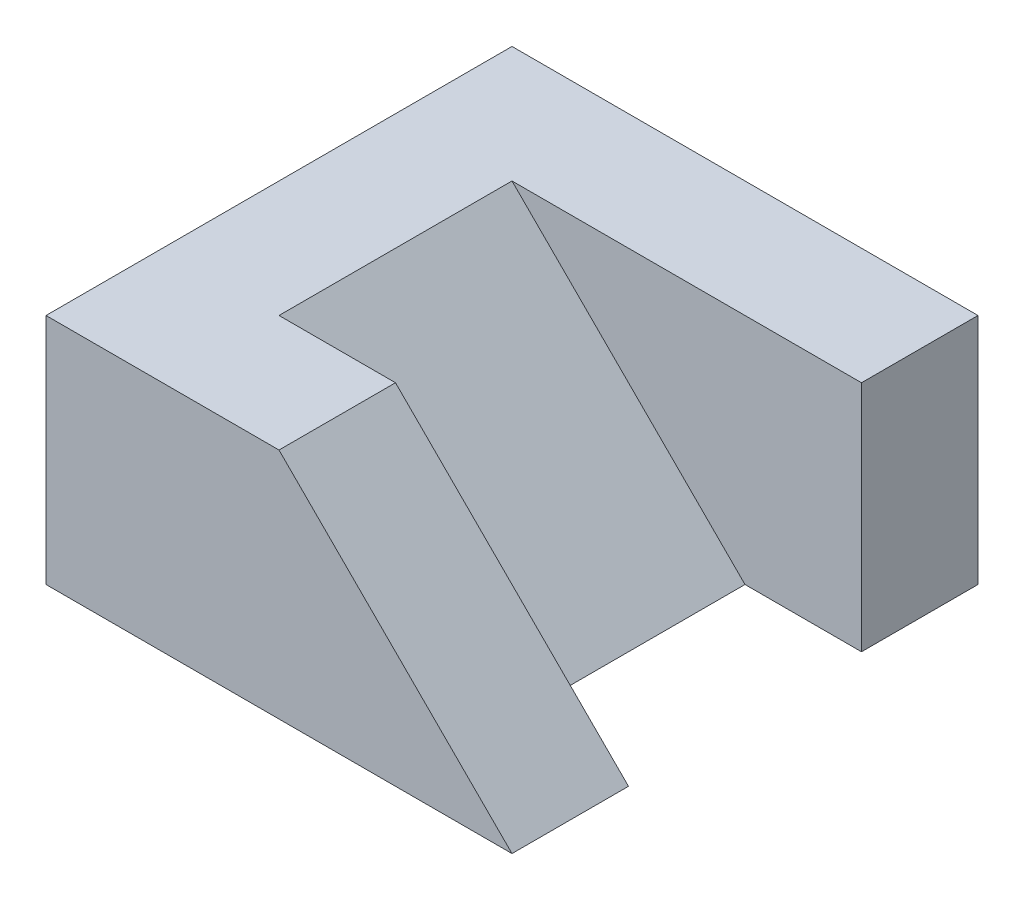
from build123d import *

# Parameters (mm, degrees)
EXTRUDE_1_DEPTH     = 10
CUT_EXTRUDE_START   = -5
CUT_EXTRUDE_1_DEPTH = 10
CUT_EXTRUDE_2_DEPTH = 5
SCALE_1_SCALE       = 0.2


with BuildPart() as part:
    # 草圖1 → 填料-伸長1 (new body)
    with BuildSketch(Plane(origin=(0, 0, 0), x_dir=(1, 0, 0), z_dir=(0, 1, 0))):
        Polygon((10, 5), (10, 10), (-10, 10), (-10, -10), (10, -10), (10, -5), (5, -5), (5, 5), align=None)
    extrude(amount=EXTRUDE_1_DEPTH)

    # 草圖2 → 除料-伸長1 (cut)
    with BuildSketch(Plane.XY.offset(10).offset(CUT_EXTRUDE_START)):
        Polygon((10, 0), (10, 10), (-5, 10), (5, 0), align=None)
    extrude(amount=-CUT_EXTRUDE_1_DEPTH, mode=Mode.SUBTRACT)

    # 草圖3 → 除料-伸長2 (cut)
    with BuildSketch(Plane.XY.offset(10)):
        Polygon((0, 10), (10, 0), (10, 10), align=None)
    extrude(amount=-CUT_EXTRUDE_2_DEPTH, mode=Mode.SUBTRACT)


with BuildPart() as part_1:
    # 縮放比例1: scaled about (-2.272727273, 4.545454545, -0.681818182)
    add(part.part.scale(SCALE_1_SCALE).moved(Location((-1.818181818, 3.636363636, -0.545454546))))


solid = part_1.part
